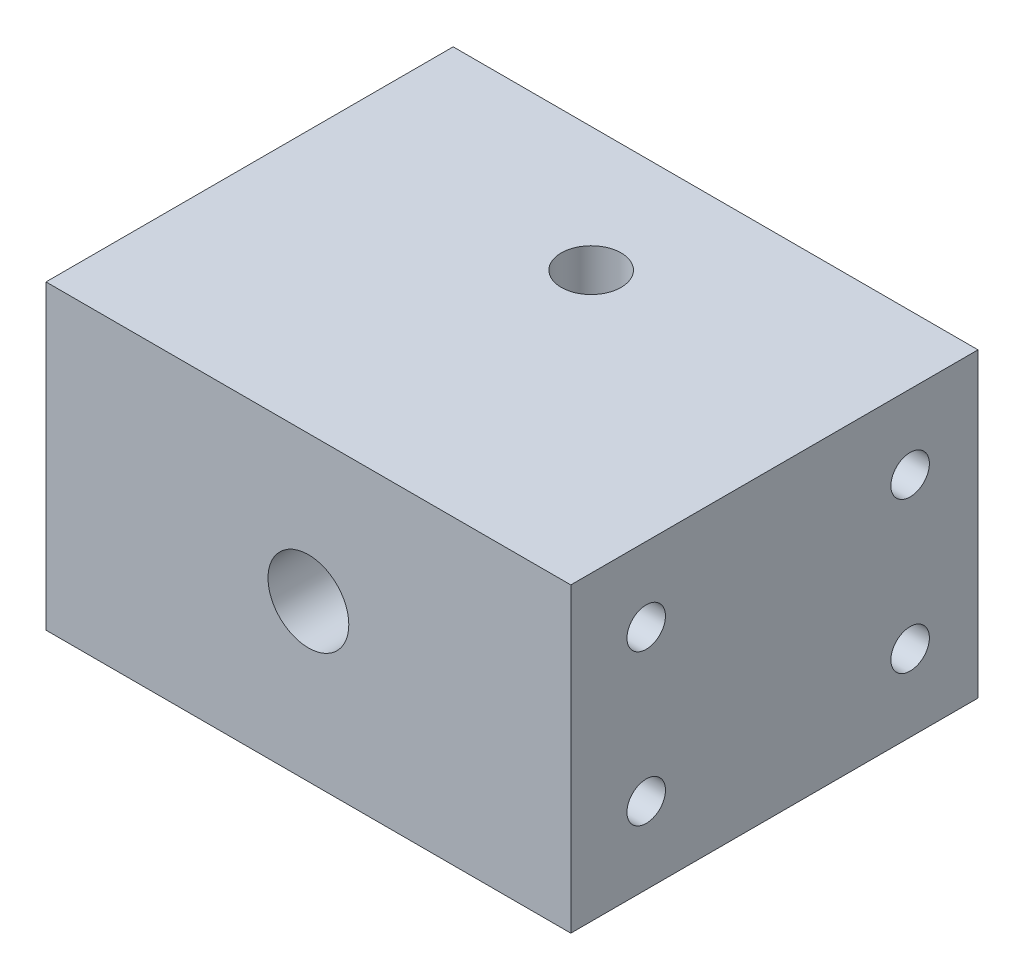
from build123d import *

# Parameters (mm, degrees)
SKETCH1_W                        = 69.6
SKETCH1_H                        = 75
BOSS_EXTRUDE1_DEPTH              = 40
SKETCH3_W                        = 126.991899018
SKETCH3_H                        = 42.64725952
CUT_EXTRUDE2_DEPTH               = 41
F_3_8_16_TAPPED_HOLE1_D          = 7.9375
F_3_8_16_TAPPED_HOLE1_DEPTH      = 15.875
F_3_8_16_TAPPED_HOLE1_TIP        = 2.384665582
F_1_4_20_TAPPED_HOLE1_AT_2_COUNT = 2
F_1_4_20_TAPPED_HOLE1_AT_2_PITCH = 20
F_1_4_20_TAPPED_HOLE1_AT_3_COUNT = 2
F_1_4_20_TAPPED_HOLE1_AT_3_PITCH = 40.311288741
F_1_4_20_TAPPED_HOLE1_AT_4_COUNT = 2
F_1_4_20_TAPPED_HOLE1_AT_4_PITCH = 35
CUT_EXTRUDE3_DEPTH               = 20
F_1_2_13_TAPPED_HOLE1_D          = 10.71626
F_1_2_13_TAPPED_HOLE1_DEPTH      = 25
F_1_2_13_TAPPED_HOLE1_TIP        = 3.219489309
FILLET1_R                        = 2


with BuildPart() as part:
    # Sketch1 → Boss-Extrude1 (new body)
    with BuildSketch(Plane(origin=(0, 0, 0), x_dir=(1, 0, 0), z_dir=(0, 1, 0))):
        Rectangle(SKETCH1_W, SKETCH1_H)
    extrude(amount=BOSS_EXTRUDE1_DEPTH)

    # Sketch3 → Cut-Extrude2 (cut, through all)
    with BuildSketch(Plane(origin=(0, 0, 0), x_dir=(1, 0, 0), z_dir=(0, 1, 0))):
        with Locations((-9.204742755, 37.82362976)):
            Rectangle(SKETCH3_W, SKETCH3_H)
    extrude(amount=CUT_EXTRUDE2_DEPTH, mode=Mode.SUBTRACT)

    # 3/8-16 Tapped Hole1
    with Locations(Plane(origin=(0, 40, 0), x_dir=(1, 0, 0), z_dir=(0, 1, 0))):
        with Locations((0, 0)):
            Hole(F_3_8_16_TAPPED_HOLE1_D / 2, depth=F_3_8_16_TAPPED_HOLE1_DEPTH)
            with Locations((0, 0, -(F_3_8_16_TAPPED_HOLE1_DEPTH + F_3_8_16_TAPPED_HOLE1_TIP / 2))):  # 118° drill point
                Cone(0, F_3_8_16_TAPPED_HOLE1_D / 2, F_3_8_16_TAPPED_HOLE1_TIP, mode=Mode.SUBTRACT)

    # Sketch10 → 1/4-20 Tapped Hole1 (revolve, cut)
    with BuildSketch(Plane(origin=(34.8, 30.16, -7.5), x_dir=(0, 0, -1), z_dir=(0, 1, 0))):
        Polygon((0, 0), (0, 14.533816902), (2.5527, 13), (2.5527, 0), align=None)
    f_1_4_20_tapped_hole1 = revolve(axis=Axis((41.15, 30.16, -7.5), (-1, 0, 0)), mode=Mode.SUBTRACT)

    # 1/4-20 Tapped Hole1 at 2: 1/4-20 Tapped Hole1 ×2
    with Locations(*[(0, -i * F_1_4_20_TAPPED_HOLE1_AT_2_PITCH, 0) for i in range(1, F_1_4_20_TAPPED_HOLE1_AT_2_COUNT)]):
        add(f_1_4_20_tapped_hole1, mode=Mode.SUBTRACT)

    # 1/4-20 Tapped Hole1 at 3: 1/4-20 Tapped Hole1 ×2
    with Locations(*[Vector(0, -0.496138938, 0.868243142) * (i * F_1_4_20_TAPPED_HOLE1_AT_3_PITCH) for i in range(1, F_1_4_20_TAPPED_HOLE1_AT_3_COUNT)]):
        add(f_1_4_20_tapped_hole1, mode=Mode.SUBTRACT)

    # 1/4-20 Tapped Hole1 at 4: 1/4-20 Tapped Hole1 ×2
    with Locations(*[(0, 0, i * F_1_4_20_TAPPED_HOLE1_AT_4_PITCH) for i in range(1, F_1_4_20_TAPPED_HOLE1_AT_4_COUNT)]):
        add(f_1_4_20_tapped_hole1, mode=Mode.SUBTRACT)

    # Mirror1: 1/4-20 Tapped Hole1 across plane
    add(f_1_4_20_tapped_hole1.mirror(Plane(origin=(0, 0, 0), x_dir=(0, 0, 1), z_dir=(1, 0, 0))), mode=Mode.SUBTRACT)

    # Mirror1 copy 1 sketch → Mirror1 copy 1 (revolve, cut)
    with BuildSketch(Plane(origin=(-34.8, 10.16, -7.5), x_dir=(0, 0, -1), z_dir=(0, 1, 0))):
        Polygon((0, 0), (0, -14.533816902), (2.5527, -13), (2.5527, 0), align=None)
    revolve(axis=Axis((-41.15, 10.16, -7.5), (-1, 0, 0)), mode=Mode.SUBTRACT)

    # Mirror1 copy 2 sketch → Mirror1 copy 2 (revolve, cut)
    with BuildSketch(Plane(origin=(-34.8, 10.16, 27.5), x_dir=(0, 0, -1), z_dir=(0, 1, 0))):
        Polygon((0, 0), (0, -14.533816902), (2.5527, -13), (2.5527, 0), align=None)
    revolve(axis=Axis((-41.15, 10.16, 27.5), (-1, 0, 0)), mode=Mode.SUBTRACT)

    # Mirror1 copy 3 sketch → Mirror1 copy 3 (revolve, cut)
    with BuildSketch(Plane(origin=(-34.8, 30.16, 27.5), x_dir=(0, 0, -1), z_dir=(0, 1, 0))):
        Polygon((0, 0), (0, -14.533816902), (2.5527, -13), (2.5527, 0), align=None)
    revolve(axis=Axis((-41.15, 30.16, 27.5), (-1, 0, 0)), mode=Mode.SUBTRACT)

    # Sketch11 → Cut-Extrude3 (cut, symmetric)
    with BuildSketch(Plane(origin=(0, 0, 0), x_dir=(0, 0, -1), z_dir=(1, 0, 0))):
        Polygon((20.112673013, 20.996619633), (-33.5, -4.003380367), (20.112673013, -4.003380367), align=None)
    extrude(amount=CUT_EXTRUDE3_DEPTH, both=True, mode=Mode.SUBTRACT)

    # 1/2-13 Tapped Hole1
    with Locations(Plane.XY.offset(37.5)):
        with Locations((0, 20.718863156)):
            Hole(F_1_2_13_TAPPED_HOLE1_D / 2, depth=F_1_2_13_TAPPED_HOLE1_DEPTH)
            with Locations((0, 0, -(F_1_2_13_TAPPED_HOLE1_DEPTH + F_1_2_13_TAPPED_HOLE1_TIP / 2))):  # 118° drill point
                Cone(0, F_1_2_13_TAPPED_HOLE1_D / 2, F_1_2_13_TAPPED_HOLE1_TIP, mode=Mode.SUBTRACT)

    # Fillet1
    fillet1_edges = [part.edges().sort_by_distance(p)[0] for p in [
        (-20, 9.65600127, 4.207361549),
        (20, 9.65600127, 4.207361549),
    ]]
    fillet(fillet1_edges, radius=FILLET1_R)


solid = part.part
